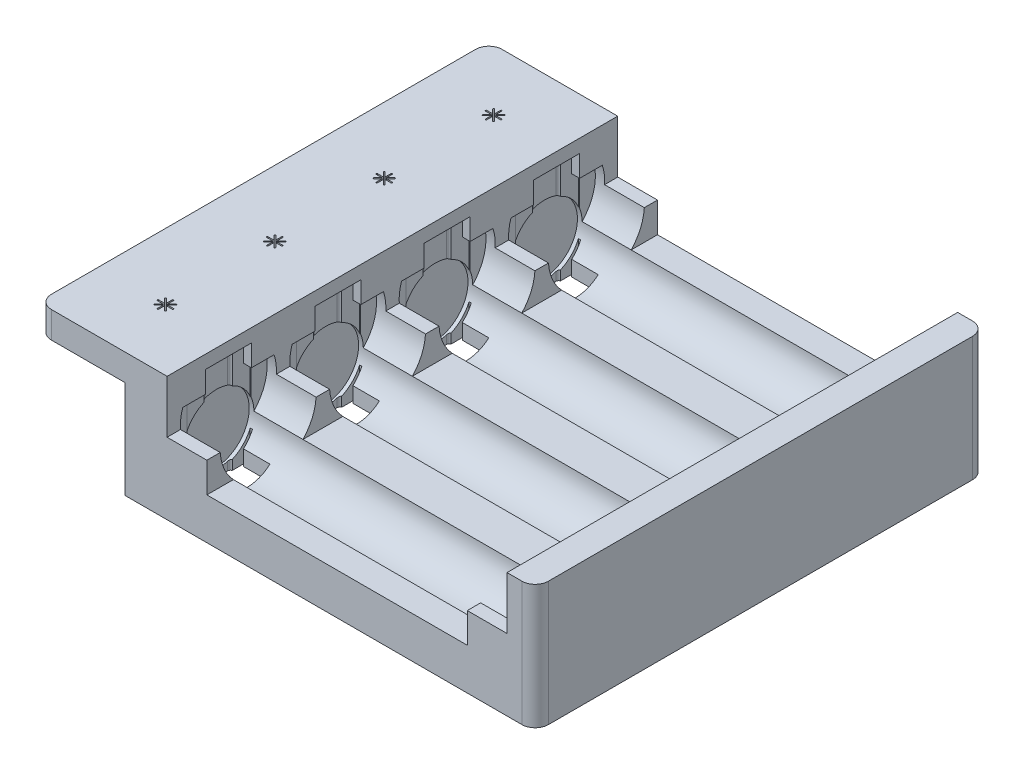
from build123d import *
from build123d.topology import SkipClean

# Parameters (mm, degrees)
EXTRUDE_1_DEPTH           = 9.25
CUT_EXTRUDE_1_DEPTH       = 9.25
SKETCH_3_W                = 0.35
SKETCH_3_H                = 9.65
CUT_EXTRUDE_4_DEPTH       = 5.25
EXTRUDE_2_DEPTH           = 13.5
CUT_EXTRUDE_5_DEPTH       = 13.5
SKETCH_10_W               = 0.303351491
SKETCH_10_H               = 9.65
CUT_EXTRUDE_6_DEPTH       = 13.5
SKETCH_11_W               = 0.332853911
SKETCH_11_H               = 9.65
CUT_EXTRUDE_7_DEPTH       = 13.5
SKETCH_14_W               = 45.296648509
SKETCH_14_H               = 7.25
CUT_EXTRUDE_8_DEPTH       = 78.5
SKETCH_17_R               = 5.25
CUT_EXTRUDE_9_DEPTH       = 46.5
CUT_EXTRUDE_9_DEPTH_BACK  = 2.110543338
SKETCH_18_W               = 4.00304366
SKETCH_18_H               = 6.943093373
CUT_EXTRUDE_10_DEPTH      = 2.36
SKETCH_19_W               = 4
SKETCH_19_H               = 6.948667875
CUT_EXTRUDE_11_DEPTH      = 2.36
CUT_EXTRUDE_12_DEPTH      = 70.36
EXTRUDE_3_DEPTH           = 5.25
SKETCH_22_R               = 7.25
CUT_EXTRUDE_14_DEPTH      = 46.7
CUT_EXTRUDE_14_DEPTH_BACK = 7.4
CUT_EXTRUDE_16_DEPTH      = 55.7
SKETCH_27_W               = 68
SKETCH_27_H               = 7.964243416
CUT_EXTRUDE_17_DEPTH      = 6
SKETCH_28_W               = 68
SKETCH_28_H               = 5.25
EXTRUDE_4_DEPTH           = 6.351675745
CUT_EXTRUDE_18_DEPTH      = 18.75
EXTRUDE_5_DEPTH           = 6
SKETCH_32_W               = 68
SKETCH_32_H               = 7.964243416
CUT_EXTRUDE_19_DEPTH      = 45.29664851
SKETCH_33_W               = 6.351675746
SKETCH_33_H               = 68
SKETCH_33_W_2             = 2.246675745
EXTRUDE_6_DEPTH           = 2
SKETCH_34_W               = 68
SKETCH_34_H               = 4
EXTRUDE_8_DEPTH           = 13.868
CUT_EXTRUDE_21_DEPTH      = 13.868
CUT_EXTRUDE_23_DEPTH      = 44.868
SKETCH_38_R               = 3.6
SKETCH_38_R_2             = 2.6
EXTRUDE_12_DEPTH          = 11
CUT_EXTRUDE_26_DEPTH      = 32
CUT_EXTRUDE_27_DEPTH      = 10000


with BuildPart() as part:
    # 草图1 → 凸台-拉伸1 (new body)
    with BuildSketch(Plane(origin=(0, 0, 0), x_dir=(1, 0, 0), z_dir=(0, 1, 0))):
        with BuildLine():
            Line((1.473912597, 27.479371635), (61.368912597, 27.479371635))
            ThreePointArc((61.368912597, 27.479371635), (62.78312616, 26.893585197), (63.368912597, 25.479371635))
            Line((63.368912597, 25.479371635), (63.368912597, -38.520628365))
            ThreePointArc((63.368912597, -38.520628365), (62.78312616, -39.934841927), (61.368912597, -40.520628365))
            Line((61.368912597, -40.520628365), (1.473912597, -40.520628365))
            Line((1.473912597, -40.520628365), (1.473912597, 27.479371635))
        make_face()
    extrude(amount=EXTRUDE_1_DEPTH)

    # 草图2 → 切除-拉伸1 (cut)
    with BuildSketch(Plane(origin=(0, 9.25, 0), x_dir=(1, 0, 0), z_dir=(0, 1, 0))):
        with BuildLine():
            Line((54.923912597, -29.570628365), (54.923912597, -32.970628365))
            ThreePointArc((54.923912597, -32.970628365), (54.473912597, -33.420628365), (54.023912597, -32.970628365))
            Line((54.023912597, -32.970628365), (54.023912597, -29.570628365))
            ThreePointArc((54.023912597, -29.570628365), (54.473912597, -29.120628365), (54.923912597, -29.570628365))
        make_face()
        with BuildLine():
            Line((54.923912597, -13.060628365), (54.923912597, -16.460628365))
            ThreePointArc((54.923912597, -16.460628365), (54.473912597, -16.910628365), (54.023912597, -16.460628365))
            Line((54.023912597, -16.460628365), (54.023912597, -13.060628365))
            ThreePointArc((54.023912597, -13.060628365), (54.473912597, -12.610628365), (54.923912597, -13.060628365))
        make_face()
        with BuildLine():
            Line((54.923912597, 3.449371635), (54.923912597, 0.049371635))
            ThreePointArc((54.923912597, 0.049371635), (54.473912597, -0.400628365), (54.023912597, 0.049371635))
            Line((54.023912597, 0.049371635), (54.023912597, 3.449371635))
            ThreePointArc((54.023912597, 3.449371635), (54.473912597, 3.899371635), (54.923912597, 3.449371635))
        make_face()
        with BuildLine():
            Line((54.923912597, 19.959371635), (54.923912597, 16.559371635))
            ThreePointArc((54.923912597, 16.559371635), (54.473912597, 16.109371635), (54.023912597, 16.559371635))
            Line((54.023912597, 16.559371635), (54.023912597, 19.959371635))
            ThreePointArc((54.023912597, 19.959371635), (54.473912597, 20.409371635), (54.923912597, 19.959371635))
        make_face()
    extrude(amount=-CUT_EXTRUDE_1_DEPTH, mode=Mode.SUBTRACT)

    # 草图3 → 切除-拉伸4 (cut)
    with BuildSketch(Plane(origin=(0, 9.25, 0), x_dir=(1, 0, 0), z_dir=(0, 1, 0))):
        with Locations((54.473912597, -14.760628365)):
            Rectangle(SKETCH_3_W, SKETCH_3_H)
        with Locations((54.473912597, -31.270628365)):
            Rectangle(SKETCH_3_W, SKETCH_3_H)
        with Locations((54.473912597, 1.749371635)):
            Rectangle(SKETCH_3_W, SKETCH_3_H)
        with Locations((54.473912597, 18.259371635)):
            Rectangle(SKETCH_3_W, SKETCH_3_H)
    extrude(amount=-CUT_EXTRUDE_4_DEPTH, mode=Mode.SUBTRACT)

    # 草图7 → 凸台-拉伸2 (add)
    with BuildSketch(Plane.XZ):
        with BuildLine():
            Line((61.368912597, -27.479371635), (1.473912597, -27.479371635))
            Line((1.473912597, -27.479371635), (1.473912597, 40.520628365))
            Line((1.473912597, 40.520628365), (61.368912597, 40.520628365))
            ThreePointArc((61.368912597, 40.520628365), (62.78312616, 39.934841927), (63.368912597, 38.520628365))
            Line((63.368912597, 38.520628365), (63.368912597, -25.479371635))
            ThreePointArc((63.368912597, -25.479371635), (62.78312616, -26.893585197), (61.368912597, -27.479371635))
        make_face()
    extrude(amount=-EXTRUDE_2_DEPTH)

    # 草图9 → 切除-拉伸5 (cut)
    with BuildSketch(Plane(origin=(0, 13.5, 0), x_dir=(1, 0, 0), z_dir=(0, 1, 0))):
        with BuildLine():
            Line((54.023912597, -32.970628365), (54.023912597, -29.570628365))
            ThreePointArc((54.023912597, -29.570628365), (54.473912597, -29.120628365), (54.923912597, -29.570628365))
            Line((54.923912597, -29.570628365), (54.923912597, -32.970628365))
            ThreePointArc((54.923912597, -32.970628365), (54.473912597, -33.420628365), (54.023912597, -32.970628365))
        make_face()
        with BuildLine():
            Line((54.023912597, -16.460628365), (54.023912597, -13.060628365))
            ThreePointArc((54.023912597, -13.060628365), (54.473912597, -12.610628365), (54.923912597, -13.060628365))
            Line((54.923912597, -13.060628365), (54.923912597, -16.460628365))
            ThreePointArc((54.923912597, -16.460628365), (54.473912597, -16.910628365), (54.023912597, -16.460628365))
        make_face()
        with BuildLine():
            Line((54.023912597, 0.049371635), (54.023912597, 3.449371635))
            ThreePointArc((54.023912597, 3.449371635), (54.473912597, 3.899371635), (54.923912597, 3.449371635))
            Line((54.923912597, 3.449371635), (54.923912597, 0.049371635))
            ThreePointArc((54.923912597, 0.049371635), (54.473912597, -0.400628365), (54.023912597, 0.049371635))
        make_face()
        with BuildLine():
            Line((54.023912597, 16.559371635), (54.023912597, 19.959371635))
            ThreePointArc((54.023912597, 19.959371635), (54.473912597, 20.409371635), (54.923912597, 19.959371635))
            Line((54.923912597, 19.959371635), (54.923912597, 16.559371635))
            ThreePointArc((54.923912597, 16.559371635), (54.473912597, 16.109371635), (54.023912597, 16.559371635))
        make_face()
    extrude(amount=-CUT_EXTRUDE_5_DEPTH, mode=Mode.SUBTRACT)

    # 草图10 → 切除-拉伸6 (cut)
    with BuildSketch(Plane(origin=(0, 13.5, 0), x_dir=(1, 0, 0), z_dir=(0, 1, 0))):
        with Locations((54.473912598, -14.760628365)):
            Rectangle(SKETCH_10_W, SKETCH_10_H)
        with Locations((54.473912598, -31.270628365)):
            Rectangle(SKETCH_10_W, SKETCH_10_H)
        with Locations((54.473912598, 1.749371635)):
            Rectangle(SKETCH_10_W, SKETCH_10_H)
        with Locations((54.473912598, 18.259371635)):
            Rectangle(SKETCH_10_W, SKETCH_10_H)
    extrude(amount=-CUT_EXTRUDE_6_DEPTH, mode=Mode.SUBTRACT)

    # 草图11 → 切除-拉伸7 (cut)
    with BuildSketch(Plane(origin=(0, 13.5, 0), x_dir=(1, 0, 0), z_dir=(0, 1, 0))):
        with BuildLine():
            Line((6.009161387, -32.970628365), (6.009161387, -29.570628365))
            ThreePointArc((6.009161387, -29.570628365), (6.459161387, -29.120628365), (6.909161387, -29.570628365))
            Line((6.909161387, -29.570628365), (6.909161387, -32.970628365))
            ThreePointArc((6.909161387, -32.970628365), (6.459161387, -33.420628365), (6.009161387, -32.970628365))
        make_face()
        with Locations((6.459161388, -14.760628365)):
            Rectangle(SKETCH_11_W, SKETCH_11_H)
        with Locations((6.459161388, -31.270628365)):
            Rectangle(SKETCH_11_W, SKETCH_11_H)
        with BuildLine():
            Line((6.009161387, -16.460628365), (6.009161387, -13.060628365))
            ThreePointArc((6.009161387, -13.060628365), (6.459161387, -12.610628365), (6.909161387, -13.060628365))
            Line((6.909161387, -13.060628365), (6.909161387, -16.460628365))
            ThreePointArc((6.909161387, -16.460628365), (6.459161387, -16.910628365), (6.009161387, -16.460628365))
        make_face()
        with Locations((6.459161388, 1.749371635)):
            Rectangle(SKETCH_11_W, SKETCH_11_H)
        with BuildLine():
            Line((6.009161387, 0.049371635), (6.009161387, 3.449371635))
            ThreePointArc((6.009161387, 3.449371635), (6.459161387, 3.899371635), (6.909161387, 3.449371635))
            Line((6.909161387, 3.449371635), (6.909161387, 0.049371635))
            ThreePointArc((6.909161387, 0.049371635), (6.459161387, -0.400628365), (6.009161387, 0.049371635))
        make_face()
        with Locations((6.459161388, 18.259371635)):
            Rectangle(SKETCH_11_W, SKETCH_11_H)
        with BuildLine():
            Line((6.009161387, 16.559371635), (6.009161387, 19.959371635))
            ThreePointArc((6.009161387, 19.959371635), (6.459161387, 20.409371635), (6.909161387, 19.959371635))
            Line((6.909161387, 19.959371635), (6.909161387, 16.559371635))
            ThreePointArc((6.909161387, 16.559371635), (6.459161387, 16.109371635), (6.009161387, 16.559371635))
        make_face()
    extrude(amount=-CUT_EXTRUDE_7_DEPTH, mode=Mode.SUBTRACT)

    # 草图14 → 切除-拉伸8 (cut)
    with BuildSketch(Plane.XY.offset(40.520628365)):
        with Locations((30.473912598, 9.875)):
            Rectangle(SKETCH_14_W, SKETCH_14_H)
    extrude(amount=-CUT_EXTRUDE_8_DEPTH, mode=Mode.SUBTRACT)

    # 草图17 → 切除-拉伸9 (cut, two sides)
    with BuildSketch(Plane(origin=(7.825588343, 0, 0), x_dir=(0, 0, -1), z_dir=(1, 0, 0))) as cut_extrude_9_sk:
        with Locations(Location((-31.270628365, 6.25, 0), (0, 0, 90))):
            Circle(SKETCH_17_R)
        with Locations(Location((-14.760628365, 6.25, 0), (0, 0, 90))):
            Circle(SKETCH_17_R)
        with Locations(Location((1.749371635, 6.25, 0), (0, 0, 90))):
            Circle(SKETCH_17_R)
        with Locations(Location((18.259371635, 6.25, 0), (0, 0, 90))):
            Circle(SKETCH_17_R)
    extrude(amount=CUT_EXTRUDE_9_DEPTH, mode=Mode.SUBTRACT)
    extrude(cut_extrude_9_sk.sketch, amount=-CUT_EXTRUDE_9_DEPTH_BACK, mode=Mode.SUBTRACT)

    # 草图18 → 切除-拉伸10 (cut)
    with BuildSketch(Plane.XZ):
        with Locations((8.627110173, 31.270628366)):
            Rectangle(SKETCH_18_W, SKETCH_18_H)
        with Locations((8.627110173, 14.760628366)):
            Rectangle(SKETCH_18_W, SKETCH_18_H)
        with Locations((8.627110173, -1.749371635)):
            Rectangle(SKETCH_18_W, SKETCH_18_H)
        with Locations((8.627110173, -18.259371634)):
            Rectangle(SKETCH_18_W, SKETCH_18_H)
    extrude(amount=-CUT_EXTRUDE_10_DEPTH, mode=Mode.SUBTRACT)

    # 草图19 → 切除-拉伸11 (cut)
    with BuildSketch(Plane.XZ):
        with Locations((52.322236852, 31.270628366)):
            Rectangle(SKETCH_19_W, SKETCH_19_H)
        with Locations((52.322236852, 14.760628366)):
            Rectangle(SKETCH_19_W, SKETCH_19_H)
        with Locations((52.322236852, -1.749371635)):
            Rectangle(SKETCH_19_W, SKETCH_19_H)
        with Locations((52.322236852, -18.259371635)):
            Rectangle(SKETCH_19_W, SKETCH_19_H)
    extrude(amount=-CUT_EXTRUDE_11_DEPTH, mode=Mode.SUBTRACT)

    # 草图20 → 切除-拉伸12 (cut)
    with BuildSketch(Plane(origin=(0, 13.5, 0), x_dir=(1, 0, 0), z_dir=(0, 1, 0))):
        with BuildLine():
            Line((60.322236852, -36.095628365), (60.625588343, -36.095628365))
            Line((60.625588343, -36.095628365), (60.625588343, -33.39429624))
            ThreePointArc((60.625588343, -33.39429624), (60.841848791, -33.229709351), (60.923912597, -32.970628365))
            Line((60.923912597, -32.970628365), (60.923912597, -29.570628365))
            ThreePointArc((60.923912597, -29.570628365), (60.841848791, -29.311547379), (60.625588343, -29.14696049))
            Line((60.625588343, -29.14696049), (60.625588343, -26.445628365))
            Line((60.625588343, -26.445628365), (60.322236852, -26.445628365))
            Line((60.322236852, -26.445628365), (60.322236852, -29.14696049))
            ThreePointArc((60.322236852, -29.14696049), (60.105976404, -29.311547379), (60.023912597, -29.570628365))
            Line((60.023912597, -29.570628365), (60.023912597, -32.970628365))
            ThreePointArc((60.023912597, -32.970628365), (60.105976404, -33.229709351), (60.322236852, -33.39429624))
            Line((60.322236852, -33.39429624), (60.322236852, -36.095628365))
        make_face()
        with BuildLine():
            Line((60.322236852, -19.585628365), (60.625588343, -19.585628365))
            Line((60.625588343, -19.585628365), (60.625588343, -16.88429624))
            ThreePointArc((60.625588343, -16.88429624), (60.841848791, -16.719709351), (60.923912597, -16.460628365))
            Line((60.923912597, -16.460628365), (60.923912597, -13.060628365))
            ThreePointArc((60.923912597, -13.060628365), (60.841848791, -12.801547379), (60.625588343, -12.63696049))
            Line((60.625588343, -12.63696049), (60.625588343, -9.935628365))
            Line((60.625588343, -9.935628365), (60.322236852, -9.935628365))
            Line((60.322236852, -9.935628365), (60.322236852, -12.63696049))
            ThreePointArc((60.322236852, -12.63696049), (60.105976404, -12.801547379), (60.023912597, -13.060628365))
            Line((60.023912597, -13.060628365), (60.023912597, -16.460628365))
            ThreePointArc((60.023912597, -16.460628365), (60.105976404, -16.719709351), (60.322236852, -16.88429624))
            Line((60.322236852, -16.88429624), (60.322236852, -19.585628365))
        make_face()
        with BuildLine():
            Line((60.322236852, -3.075628365), (60.625588343, -3.075628365))
            Line((60.625588343, -3.075628365), (60.625588343, -0.37429624))
            ThreePointArc((60.625588343, -0.37429624), (60.841848791, -0.209709351), (60.923912597, 0.049371635))
            Line((60.923912597, 0.049371635), (60.923912597, 3.449371635))
            ThreePointArc((60.923912597, 3.449371635), (60.841848791, 3.708452621), (60.625588343, 3.87303951))
            Line((60.625588343, 3.87303951), (60.625588343, 6.574371635))
            Line((60.625588343, 6.574371635), (60.322236852, 6.574371635))
            Line((60.322236852, 6.574371635), (60.322236852, 3.87303951))
            ThreePointArc((60.322236852, 3.87303951), (60.105976404, 3.708452621), (60.023912597, 3.449371635))
            Line((60.023912597, 3.449371635), (60.023912597, 0.049371635))
            ThreePointArc((60.023912597, 0.049371635), (60.105976404, -0.209709351), (60.322236852, -0.37429624))
            Line((60.322236852, -0.37429624), (60.322236852, -3.075628365))
        make_face()
        with BuildLine():
            Line((54.322236852, -19.585628365), (54.625588343, -19.585628365))
            Line((54.625588343, -19.585628365), (54.625588343, -16.88429624))
            ThreePointArc((54.625588343, -16.88429624), (54.841848791, -16.719709351), (54.923912597, -16.460628365))
            Line((54.923912597, -16.460628365), (54.923912597, -13.060628365))
            ThreePointArc((54.923912597, -13.060628365), (54.841848791, -12.801547379), (54.625588343, -12.63696049))
            Line((54.625588343, -12.63696049), (54.625588343, -9.935628365))
            Line((54.625588343, -9.935628365), (54.322236852, -9.935628365))
            Line((54.322236852, -9.935628365), (54.322236852, -12.63696049))
            ThreePointArc((54.322236852, -12.63696049), (54.105976404, -12.801547379), (54.023912597, -13.060628365))
            Line((54.023912597, -13.060628365), (54.023912597, -16.460628365))
            ThreePointArc((54.023912597, -16.460628365), (54.105976404, -16.719709351), (54.322236852, -16.88429624))
            Line((54.322236852, -16.88429624), (54.322236852, -19.585628365))
        make_face()
        with BuildLine():
            Line((60.322236852, 13.434371635), (60.625588343, 13.434371635))
            Line((60.625588343, 13.434371635), (60.625588343, 16.13570376))
            ThreePointArc((60.625588343, 16.13570376), (60.841848791, 16.300290649), (60.923912597, 16.559371635))
            Line((60.923912597, 16.559371635), (60.923912597, 19.959371635))
            ThreePointArc((60.923912597, 19.959371635), (60.841848791, 20.218452621), (60.625588343, 20.38303951))
            Line((60.625588343, 20.38303951), (60.625588343, 23.084371635))
            Line((60.625588343, 23.084371635), (60.322236852, 23.084371635))
            Line((60.322236852, 23.084371635), (60.322236852, 20.38303951))
            ThreePointArc((60.322236852, 20.38303951), (60.105976404, 20.218452621), (60.023912597, 19.959371635))
            Line((60.023912597, 19.959371635), (60.023912597, 16.559371635))
            ThreePointArc((60.023912597, 16.559371635), (60.105976404, 16.300290649), (60.322236852, 16.13570376))
            Line((60.322236852, 16.13570376), (60.322236852, 13.434371635))
        make_face()
    extrude(amount=-CUT_EXTRUDE_12_DEPTH, mode=Mode.SUBTRACT)

    # 草图21 → 凸台-拉伸3 (add)
    with BuildSketch(Plane(origin=(0, 13.5, 0), x_dir=(1, 0, 0), z_dir=(0, 1, 0))):
        with BuildLine():
            Line((61.368912597, 27.479371635), (53.122236852, 27.479371635))
            Line((53.122236852, 27.479371635), (53.122236852, -40.520628365))
            Line((53.122236852, -40.520628365), (61.368912597, -40.520628365))
            ThreePointArc((61.368912597, -40.520628365), (62.78312616, -39.934841927), (63.368912597, -38.520628365))
            Line((63.368912597, -38.520628365), (63.368912597, 25.479371635))
            ThreePointArc((63.368912597, 25.479371635), (62.78312616, 26.893585197), (61.368912597, 27.479371635))
        make_face()
    extrude(amount=EXTRUDE_3_DEPTH)

    # 草图22 → 切除-拉伸14 (cut, two sides)
    with BuildSketch(Plane.ZY.offset(-53.122236852)) as cut_extrude_14_sk:
        with Locations(Location((-1.749371635, 11.25, 0), (0, 0, 311.722018983))):
            Circle(SKETCH_22_R)
        with Locations(Location((31.270628365, 11.25, 0), (0, 0, 311.722018983))):
            Circle(SKETCH_22_R)
        with Locations(Location((-18.259371635, 11.25, 0), (0, 0, 311.722018983))):
            Circle(SKETCH_22_R)
        with Locations(Location((14.760628365, 11.25, 0), (0, 0, 311.722018983))):
            Circle(SKETCH_22_R)
    extrude(amount=CUT_EXTRUDE_14_DEPTH, mode=Mode.SUBTRACT)
    extrude(cut_extrude_14_sk.sketch, amount=-CUT_EXTRUDE_14_DEPTH_BACK, mode=Mode.SUBTRACT)

    # 草图25 → 切除-拉伸16 (cut)
    with BuildSketch(Plane.XZ):
        with BuildLine():
            Line((60.625588343, -23.084371635), (60.625588343, -20.377465008))
            ThreePointArc((60.625588343, -20.377465008), (60.840370352, -20.215202581), (60.924104468, -19.95937255))
            Line((60.924104468, -19.95937255), (60.924104468, -16.55937072))
            ThreePointArc((60.924104468, -16.55937072), (60.840370352, -16.303540689), (60.625588343, -16.141278262))
            Line((60.625588343, -16.141278262), (60.625588343, -13.434371635))
            Line((60.625588343, -13.434371635), (60.275588343, -13.434371635))
            Line((60.275588343, -13.434371635), (60.275588343, -14.787824948))
            Line((60.275588343, -14.787824948), (56.936654501, -14.787824948))
            Line((56.936654501, -14.787824948), (56.936654501, -21.730918321))
            Line((56.936654501, -21.730918321), (60.275588343, -21.730918321))
            Line((60.275588343, -21.730918321), (60.275588343, -23.084371635))
            Line((60.275588343, -23.084371635), (60.625588343, -23.084371635))
        make_face()
        with BuildLine():
            Line((60.625588343, -6.574371635), (60.625588343, -3.867465008))
            ThreePointArc((60.625588343, -3.867465008), (60.840370352, -3.705202581), (60.924104468, -3.44937255))
            Line((60.924104468, -3.44937255), (60.924104468, -0.04937072))
            ThreePointArc((60.924104468, -0.04937072), (60.840370352, 0.206459311), (60.625588343, 0.368721738))
            Line((60.625588343, 0.368721738), (60.625588343, 3.075628365))
            Line((60.625588343, 3.075628365), (60.275588343, 3.075628365))
            Line((60.275588343, 3.075628365), (60.275588343, 1.722175052))
            Line((60.275588343, 1.722175052), (56.936654501, 1.722175052))
            Line((56.936654501, 1.722175052), (56.936654501, -5.220918321))
            Line((56.936654501, -5.220918321), (60.275588343, -5.220918321))
            Line((60.275588343, -5.220918321), (60.275588343, -6.574371635))
            Line((60.275588343, -6.574371635), (60.625588343, -6.574371635))
        make_face()
        with BuildLine():
            Line((60.625588343, 9.935628365), (60.625588343, 12.642534992))
            ThreePointArc((60.625588343, 12.642534992), (60.840370352, 12.804797419), (60.924104468, 13.06062745))
            Line((60.924104468, 13.06062745), (60.924104468, 16.46062928))
            ThreePointArc((60.924104468, 16.46062928), (60.840370352, 16.716459311), (60.625588343, 16.878721738))
            Line((60.625588343, 16.878721738), (60.625588343, 19.585628365))
            Line((60.625588343, 19.585628365), (60.275588343, 19.585628365))
            Line((60.275588343, 19.585628365), (60.275588343, 18.232175052))
            Line((60.275588343, 18.232175052), (56.936654501, 18.232175052))
            Line((56.936654501, 18.232175052), (56.936654501, 11.289081679))
            Line((56.936654501, 11.289081679), (60.275588343, 11.289081679))
            Line((60.275588343, 11.289081679), (60.275588343, 9.935628365))
            Line((60.275588343, 9.935628365), (60.625588343, 9.935628365))
        make_face()
        with BuildLine():
            Line((60.625588343, 26.445628365), (60.625588343, 29.152534992))
            ThreePointArc((60.625588343, 29.152534992), (60.840370352, 29.314797419), (60.924104468, 29.57062745))
            Line((60.924104468, 29.57062745), (60.924104468, 32.97062928))
            ThreePointArc((60.924104468, 32.97062928), (60.840370352, 33.226459311), (60.625588343, 33.388721738))
            Line((60.625588343, 33.388721738), (60.625588343, 36.095628365))
            Line((60.625588343, 36.095628365), (60.275588343, 36.095628365))
            Line((60.275588343, 36.095628365), (60.275588343, 34.742175052))
            Line((60.275588343, 34.742175052), (56.936654501, 34.742175052))
            Line((56.936654501, 34.742175052), (56.936654501, 27.799081679))
            Line((56.936654501, 27.799081679), (60.275588343, 27.799081679))
            Line((60.275588343, 27.799081679), (60.275588343, 26.445628365))
            Line((60.275588343, 26.445628365), (60.625588343, 26.445628365))
        make_face()
    extrude(amount=-CUT_EXTRUDE_16_DEPTH, mode=Mode.SUBTRACT)

    # 草图27 → 切除-拉伸17 (cut)
    with BuildSketch(Plane.ZY.offset(-53.122236852)):
        with Locations((6.520628365, 14.767878292)):
            Rectangle(SKETCH_27_W, SKETCH_27_H)
    extrude(amount=-CUT_EXTRUDE_17_DEPTH, mode=Mode.SUBTRACT)

    # 草图28 → 凸台-拉伸4 (add)
    with BuildSketch(Plane(origin=(7.825588343, 0, 0), x_dir=(0, 0, -1), z_dir=(1, 0, 0))):
        with Locations((-6.520628365, 16.125)):
            Rectangle(SKETCH_28_W, SKETCH_28_H)
    extrude(amount=-EXTRUDE_4_DEPTH)

    # 草图29 → 切除-拉伸18 (cut)
    with SkipClean():  # the faces are left unmerged after this step: merging them gives an invalid solid
        with BuildSketch(Plane.XZ):
            with BuildLine():
                Line((10.628632003, 11.289081679), (10.628632003, 18.232175052))
                Line((10.628632003, 18.232175052), (6.625588343, 18.232175052))
                Line((6.625588343, 18.232175052), (6.625588343, 19.585628365))
                Line((6.625588343, 19.585628365), (6.292734432, 19.585628365))
                Line((6.292734432, 19.585628365), (6.292734432, 16.878721738))
                ThreePointArc((6.292734432, 16.878721738), (6.086742182, 16.713222773), (6.009161387, 16.460628365))
                Line((6.009161387, 16.460628365), (6.009161387, 13.060628365))
                ThreePointArc((6.009161387, 13.060628365), (6.086742182, 12.808033957), (6.292734432, 12.642534992))
                Line((6.292734432, 12.642534992), (6.292734432, 9.935628365))
                Line((6.292734432, 9.935628365), (6.625588343, 9.935628365))
                Line((6.625588343, 9.935628365), (6.625588343, 11.289081679))
                Line((6.625588343, 11.289081679), (10.628632003, 11.289081679))
            make_face()
            with BuildLine():
                Line((10.628632003, 27.799081679), (10.628632003, 34.742175052))
                Line((10.628632003, 34.742175052), (6.625588343, 34.742175052))
                Line((6.625588343, 34.742175052), (6.625588343, 36.095628365))
                Line((6.625588343, 36.095628365), (6.292734432, 36.095628365))
                Line((6.292734432, 36.095628365), (6.292734432, 33.388721738))
                ThreePointArc((6.292734432, 33.388721738), (6.086742182, 33.223222773), (6.009161387, 32.970628365))
                Line((6.009161387, 32.970628365), (6.009161387, 29.570628365))
                ThreePointArc((6.009161387, 29.570628365), (6.086742182, 29.318033957), (6.292734432, 29.152534992))
                Line((6.292734432, 29.152534992), (6.292734432, 26.445628365))
                Line((6.292734432, 26.445628365), (6.625588343, 26.445628365))
                Line((6.625588343, 26.445628365), (6.625588343, 27.799081679))
                Line((6.625588343, 27.799081679), (10.628632003, 27.799081679))
            make_face()
            with BuildLine():
                Line((10.628632003, -5.220918321), (10.628632003, 1.722175052))
                Line((10.628632003, 1.722175052), (6.625588343, 1.722175052))
                Line((6.625588343, 1.722175052), (6.625588343, 3.075628365))
                Line((6.625588343, 3.075628365), (6.292734432, 3.075628365))
                Line((6.292734432, 3.075628365), (6.292734432, 0.368721738))
                ThreePointArc((6.292734432, 0.368721738), (6.086742182, 0.203222773), (6.009161387, -0.049371635))
                Line((6.009161387, -0.049371635), (6.009161387, -3.449371635))
                ThreePointArc((6.009161387, -3.449371635), (6.086742182, -3.701966043), (6.292734432, -3.867465008))
                Line((6.292734432, -3.867465008), (6.292734432, -6.574371635))
                Line((6.292734432, -6.574371635), (6.625588343, -6.574371635))
                Line((6.625588343, -6.574371635), (6.625588343, -5.220918321))
                Line((6.625588343, -5.220918321), (10.628632003, -5.220918321))
            make_face()
            with BuildLine():
                Line((10.628632003, -21.730918321), (10.628632003, -14.787824948))
                Line((10.628632003, -14.787824948), (6.625588343, -14.787824948))
                Line((6.625588343, -14.787824948), (6.625588343, -13.434371635))
                Line((6.625588343, -13.434371635), (6.292734432, -13.434371635))
                Line((6.292734432, -13.434371635), (6.292734432, -16.141278262))
                ThreePointArc((6.292734432, -16.141278262), (6.086742182, -16.306777227), (6.009161387, -16.559371635))
                Line((6.009161387, -16.559371635), (6.009161387, -19.959371635))
                ThreePointArc((6.009161387, -19.959371635), (6.086742182, -20.211966043), (6.292734432, -20.377465008))
                Line((6.292734432, -20.377465008), (6.292734432, -23.084371635))
                Line((6.292734432, -23.084371635), (6.625588343, -23.084371635))
                Line((6.625588343, -23.084371635), (6.625588343, -21.730918321))
                Line((6.625588343, -21.730918321), (10.628632003, -21.730918321))
            make_face()
        extrude(amount=-CUT_EXTRUDE_18_DEPTH, mode=Mode.SUBTRACT)

    # 草图31 → 凸台-拉伸5 (add)
    with SkipClean():  # the faces are left unmerged after this step: merging them gives an invalid solid
        with BuildSketch(Plane(origin=(7.825588343, 0, 0), x_dir=(0, 0, -1), z_dir=(1, 0, 0))):
            with BuildLine():
                ThreePointArc((-36.520628365, 6.25), (-38.341541601, 9.64853629), (-38.162652741, 13.5))
                Line((-38.162652741, 13.5), (-40.520628365, 13.5))
                Line((-40.520628365, 13.5), (-40.520628365, 6.25))
                Line((-40.520628365, 6.25), (-36.520628365, 6.25))
            make_face()
            with BuildLine():
                ThreePointArc((-21.652652741, 13.5), (-21.831541601, 9.64853629), (-20.010628365, 6.25))
                Line((-20.010628365, 6.25), (-26.020628365, 6.25))
                ThreePointArc((-26.020628365, 6.25), (-24.199715129, 9.64853629), (-24.378603989, 13.5))
                Line((-24.378603989, 13.5), (-21.652652741, 13.5))
            make_face()
            with BuildLine():
                ThreePointArc((-5.142652741, 13.5), (-5.321541601, 9.64853629), (-3.500628365, 6.25))
                Line((-3.500628365, 6.25), (-9.510628365, 6.25))
                ThreePointArc((-9.510628365, 6.25), (-7.689715129, 9.64853629), (-7.868603989, 13.5))
                Line((-7.868603989, 13.5), (-5.142652741, 13.5))
            make_face()
            with BuildLine():
                ThreePointArc((11.367347259, 13.5), (11.188458399, 9.64853629), (13.009371635, 6.25))
                Line((13.009371635, 6.25), (6.999371635, 6.25))
                ThreePointArc((6.999371635, 6.25), (8.820284871, 9.64853629), (8.641396011, 13.5))
                Line((8.641396011, 13.5), (11.367347259, 13.5))
            make_face()
            with BuildLine():
                Line((27.479371635, 13.5), (25.151396011, 13.5))
                ThreePointArc((25.151396011, 13.5), (25.330284871, 9.64853629), (23.509371635, 6.25))
                Line((23.509371635, 6.25), (27.479371635, 6.25))
                Line((27.479371635, 6.25), (27.479371635, 13.5))
            make_face()
        extrude(amount=EXTRUDE_5_DEPTH)

    # 草图32 → 切除-拉伸19 (cut)
    with SkipClean():  # the faces are left unmerged after this step: merging them gives an invalid solid
        with BuildSketch(Plane.ZY.offset(-53.122236852)):
            with Locations((6.520628365, 14.767878292)):
                Rectangle(SKETCH_32_W, SKETCH_32_H)
        extrude(amount=CUT_EXTRUDE_19_DEPTH, mode=Mode.SUBTRACT)

    # 草图33 → 凸台-拉伸6 (add)
    with BuildSketch(Plane(origin=(0, 18.75, 0), x_dir=(1, 0, 0), z_dir=(0, 1, 0))):
        with Locations((4.64975047, -6.520628365)):
            Rectangle(SKETCH_33_W, SKETCH_33_H)
        with Locations((60.245574725, -6.520628365)):
            Rectangle(SKETCH_33_W_2, SKETCH_33_H)
    extrude(amount=-EXTRUDE_6_DEPTH)

    # 草图34 → 凸台-拉伸8 (add)
    with BuildSketch(Plane.ZY.offset(-1.473912597)):
        with Locations((6.520628365, 16.75)):
            Rectangle(SKETCH_34_W, SKETCH_34_H)
    extrude(amount=EXTRUDE_8_DEPTH)

    # 草图35 → 切除-拉伸21 (cut)
    with BuildSketch(Plane(origin=(0, 18.75, 0), x_dir=(1, 0, 0), z_dir=(0, 1, 0))):
        with BuildLine():
            ThreePointArc((-10.394087403, -40.520628365), (-11.808300965, -39.934841927), (-12.394087403, -38.520628365))
            Line((-12.394087403, -38.520628365), (-12.394087403, -40.520628365))
            Line((-12.394087403, -40.520628365), (-10.394087403, -40.520628365))
        make_face()
        with BuildLine():
            ThreePointArc((-12.394087403, 25.479371635), (-11.808300965, 26.893585197), (-10.394087403, 27.479371635))
            Line((-10.394087403, 27.479371635), (-12.394087403, 27.479371635))
            Line((-12.394087403, 27.479371635), (-12.394087403, 25.479371635))
        make_face()
    extrude(amount=-CUT_EXTRUDE_21_DEPTH, mode=Mode.SUBTRACT)

    # 草图36 → 切除-拉伸23 (cut)
    with BuildSketch(Plane(origin=(0, 0, 0), x_dir=(1, 0, 0), z_dir=(0, 1, 0))):
        with BuildLine():
            Line((-2.801754863, -31.170628365), (-0.555922362, -31.170628365))
            ThreePointArc((-0.555922362, -31.170628365), (-0.455922362, -31.270628365), (-0.555922362, -31.370628365))
            Line((-0.555922362, -31.370628365), (-2.801754863, -31.370628365))
            ThreePointArc((-2.801754863, -31.370628365), (-2.901754863, -31.270628365), (-2.801754863, -31.170628365))
        make_face()
        with BuildLine():
            Line((-2.401826497, -30.405762145), (-0.813783106, -31.993805537))
            ThreePointArc((-0.813783106, -31.993805537), (-0.813783106, -32.135226893), (-0.955204462, -32.135226893))
            Line((-0.955204462, -32.135226893), (-2.543247853, -30.547183501))
            ThreePointArc((-2.543247853, -30.547183501), (-2.543247853, -30.405762145), (-2.401826497, -30.405762145))
        make_face()
        with BuildLine():
            Line((-1.578192346, -30.147712114), (-1.578192346, -32.393544616))
            ThreePointArc((-1.578192346, -32.393544616), (-1.678192346, -32.493544616), (-1.778192346, -32.393544616))
            Line((-1.778192346, -32.393544616), (-1.778192346, -30.147712114))
            ThreePointArc((-1.778192346, -30.147712114), (-1.678192346, -30.047712114), (-1.578192346, -30.147712114))
        make_face()
        with BuildLine():
            Line((-0.813326126, -30.547640481), (-2.401369518, -32.135683872))
            ThreePointArc((-2.401369518, -32.135683872), (-2.542790874, -32.135683872), (-2.542790874, -31.994262516))
            Line((-2.542790874, -31.994262516), (-0.954747483, -30.406219124))
            ThreePointArc((-0.954747483, -30.406219124), (-0.813326126, -30.406219124), (-0.813326126, -30.547640481))
        make_face()
        with BuildLine():
            Line((-2.801754863, -14.662125388), (-0.555922362, -14.662125388))
            ThreePointArc((-0.555922362, -14.662125388), (-0.455922362, -14.762125388), (-0.555922362, -14.862125388))
            Line((-0.555922362, -14.862125388), (-2.801754863, -14.862125388))
            ThreePointArc((-2.801754863, -14.862125388), (-2.901754863, -14.762125388), (-2.801754863, -14.662125388))
        make_face()
        with BuildLine():
            Line((-2.401826497, -13.897259168), (-0.813783106, -15.485302559))
            ThreePointArc((-0.813783106, -15.485302559), (-0.813783106, -15.626723915), (-0.955204462, -15.626723915))
            Line((-0.955204462, -15.626723915), (-2.543247853, -14.038680524))
            ThreePointArc((-2.543247853, -14.038680524), (-2.543247853, -13.897259168), (-2.401826497, -13.897259168))
        make_face()
        with BuildLine():
            Line((-1.578192346, -13.639209137), (-1.578192346, -15.885041639))
            ThreePointArc((-1.578192346, -15.885041639), (-1.678192346, -15.985041639), (-1.778192346, -15.885041639))
            Line((-1.778192346, -15.885041639), (-1.778192346, -13.639209137))
            ThreePointArc((-1.778192346, -13.639209137), (-1.678192346, -13.539209137), (-1.578192346, -13.639209137))
        make_face()
        with BuildLine():
            Line((-0.813326126, -14.039137503), (-2.401369518, -15.627180895))
            ThreePointArc((-2.401369518, -15.627180895), (-2.542790874, -15.627180895), (-2.542790874, -15.485759538))
            Line((-2.542790874, -15.485759538), (-0.954747483, -13.897716147))
            ThreePointArc((-0.954747483, -13.897716147), (-0.813326126, -13.897716147), (-0.813326126, -14.039137503))
        make_face()
        with BuildLine():
            Line((-2.801754863, 1.84637759), (-0.555922362, 1.84637759))
            ThreePointArc((-0.555922362, 1.84637759), (-0.455922362, 1.74637759), (-0.555922362, 1.64637759))
            Line((-0.555922362, 1.64637759), (-2.801754863, 1.64637759))
            ThreePointArc((-2.801754863, 1.64637759), (-2.901754863, 1.74637759), (-2.801754863, 1.84637759))
        make_face()
        with BuildLine():
            Line((-2.401826497, 2.61124381), (-0.813783106, 1.023200418))
            ThreePointArc((-0.813783106, 1.023200418), (-0.813783106, 0.881779062), (-0.955204462, 0.881779062))
            Line((-0.955204462, 0.881779062), (-2.543247853, 2.469822454))
            ThreePointArc((-2.543247853, 2.469822454), (-2.543247853, 2.61124381), (-2.401826497, 2.61124381))
        make_face()
        with BuildLine():
            Line((-1.578192346, 2.869293841), (-1.578192346, 0.623461339))
            ThreePointArc((-1.578192346, 0.623461339), (-1.678192346, 0.523461339), (-1.778192346, 0.623461339))
            Line((-1.778192346, 0.623461339), (-1.778192346, 2.869293841))
            ThreePointArc((-1.778192346, 2.869293841), (-1.678192346, 2.969293841), (-1.578192346, 2.869293841))
        make_face()
        with BuildLine():
            Line((-0.813326126, 2.469365474), (-2.401369518, 0.881322083))
            ThreePointArc((-2.401369518, 0.881322083), (-2.542790874, 0.881322083), (-2.542790874, 1.022743439))
            Line((-2.542790874, 1.022743439), (-0.954747483, 2.610786831))
            ThreePointArc((-0.954747483, 2.610786831), (-0.813326126, 2.610786831), (-0.813326126, 2.469365474))
        make_face()
        with BuildLine():
            Line((-2.801754863, 18.354880567), (-0.555922362, 18.354880567))
            ThreePointArc((-0.555922362, 18.354880567), (-0.455922362, 18.254880567), (-0.555922362, 18.154880567))
            Line((-0.555922362, 18.154880567), (-2.801754863, 18.154880567))
            ThreePointArc((-2.801754863, 18.154880567), (-2.901754863, 18.254880567), (-2.801754863, 18.354880567))
        make_face()
        with BuildLine():
            Line((-2.401826497, 19.119746787), (-0.813783106, 17.531703396))
            ThreePointArc((-0.813783106, 17.531703396), (-0.813783106, 17.390282039), (-0.955204462, 17.390282039))
            Line((-0.955204462, 17.390282039), (-2.543247853, 18.978325431))
            ThreePointArc((-2.543247853, 18.978325431), (-2.543247853, 19.119746787), (-2.401826497, 19.119746787))
        make_face()
        with BuildLine():
            Line((-1.578192346, 19.377796818), (-1.578192346, 17.131964316))
            ThreePointArc((-1.578192346, 17.131964316), (-1.678192346, 17.031964316), (-1.778192346, 17.131964316))
            Line((-1.778192346, 17.131964316), (-1.778192346, 19.377796818))
            ThreePointArc((-1.778192346, 19.377796818), (-1.678192346, 19.477796818), (-1.578192346, 19.377796818))
        make_face()
        with BuildLine():
            Line((-0.813326126, 18.977868452), (-2.401369518, 17.38982506))
            ThreePointArc((-2.401369518, 17.38982506), (-2.542790874, 17.38982506), (-2.542790874, 17.531246417))
            Line((-2.542790874, 17.531246417), (-0.954747483, 19.119289808))
            ThreePointArc((-0.954747483, 19.119289808), (-0.813326126, 19.119289808), (-0.813326126, 18.977868452))
        make_face()
    extrude(amount=CUT_EXTRUDE_23_DEPTH, mode=Mode.SUBTRACT)

    # 草图38 → 凸台-拉伸12 (add)
    with BuildSketch(Plane.XZ.offset(-14.75)):
        with Locations((-1.678838613, 31.270628365)):
            Circle(SKETCH_38_R)
        with Locations(Location((-1.678838613, 31.270628365, 0), (0, 0, 270))):
            Circle(SKETCH_38_R_2, mode=Mode.SUBTRACT)
        with Locations((-1.678838613, 14.760628365)):
            Circle(SKETCH_38_R)
        with Locations(Location((-1.678838613, 14.760628365, 0), (0, 0, 270))):
            Circle(SKETCH_38_R_2, mode=Mode.SUBTRACT)
        with Locations((-1.678838613, -1.749371635)):
            Circle(SKETCH_38_R)
        with Locations(Location((-1.678838613, -1.749371635, 0), (0, 0, 270))):
            Circle(SKETCH_38_R_2, mode=Mode.SUBTRACT)
        with Locations((-1.678838613, -18.259371635)):
            Circle(SKETCH_38_R)
        with Locations(Location((-1.678838613, -18.259371635, 0), (0, 0, 270))):
            Circle(SKETCH_38_R_2, mode=Mode.SUBTRACT)
    extrude(amount=EXTRUDE_12_DEPTH)

    # 草图42 → 切除-拉伸26 (cut)
    with BuildSketch(Plane(origin=(0, 18.75, 0), x_dir=(1, 0, 0), z_dir=(0, 1, 0))):
        with BuildLine():
            ThreePointArc((-10.326532526, 27.479371635), (-11.740746088, 26.893585197), (-12.326532526, 25.479371635))
            Line((-12.326532526, 25.479371635), (-12.326532526, 24.963953508))
            Line((-12.326532526, 24.963953508), (-12.326532526, -38.005210239))
            Line((-12.326532526, -38.005210239), (-12.326532526, -38.520628365))
            ThreePointArc((-12.326532526, -38.520628365), (-11.740746088, -39.934841927), (-10.326532526, -40.520628365))
            Line((-10.326532526, -40.520628365), (-10.394087403, -40.520628365))
            ThreePointArc((-10.394087403, -40.520628365), (-11.808300965, -39.934841927), (-12.394087403, -38.520628365))
            Line((-12.394087403, -38.520628365), (-12.394087403, 25.479371635))
            ThreePointArc((-12.394087403, 25.479371635), (-11.808300965, 26.893585197), (-10.394087403, 27.479371635))
            Line((-10.394087403, 27.479371635), (-10.326532526, 27.479371635))
        make_face()
    extrude(amount=-CUT_EXTRUDE_26_DEPTH, mode=Mode.SUBTRACT)

    # 草图43 → 切除-拉伸27 (cut)
    with BuildSketch(Plane(origin=(0, 18.75, 0), x_dir=(1, 0, 0), z_dir=(0, 1, 0))):
        with BuildLine():
            ThreePointArc((-11.626532526, 25.479371635), (-11.040746088, 26.893585197), (-9.626532526, 27.479371635))
            Line((-9.626532526, 27.479371635), (-10.326532526, 27.479371635))
            ThreePointArc((-10.326532526, 27.479371635), (-11.740746088, 26.893585197), (-12.326532526, 25.479371635))
            Line((-12.326532526, 25.479371635), (-12.326532526, -38.520628365))
            ThreePointArc((-12.326532526, -38.520628365), (-11.740746088, -39.934841927), (-10.326532526, -40.520628365))
            Line((-10.326532526, -40.520628365), (-9.626532526, -40.520628365))
            ThreePointArc((-9.626532526, -40.520628365), (-11.040746088, -39.934841927), (-11.626532526, -38.520628365))
            Line((-11.626532526, -38.520628365), (-11.626532526, 25.479371635))
        make_face()
    extrude(amount=-CUT_EXTRUDE_27_DEPTH, mode=Mode.SUBTRACT)


solid = part.part
